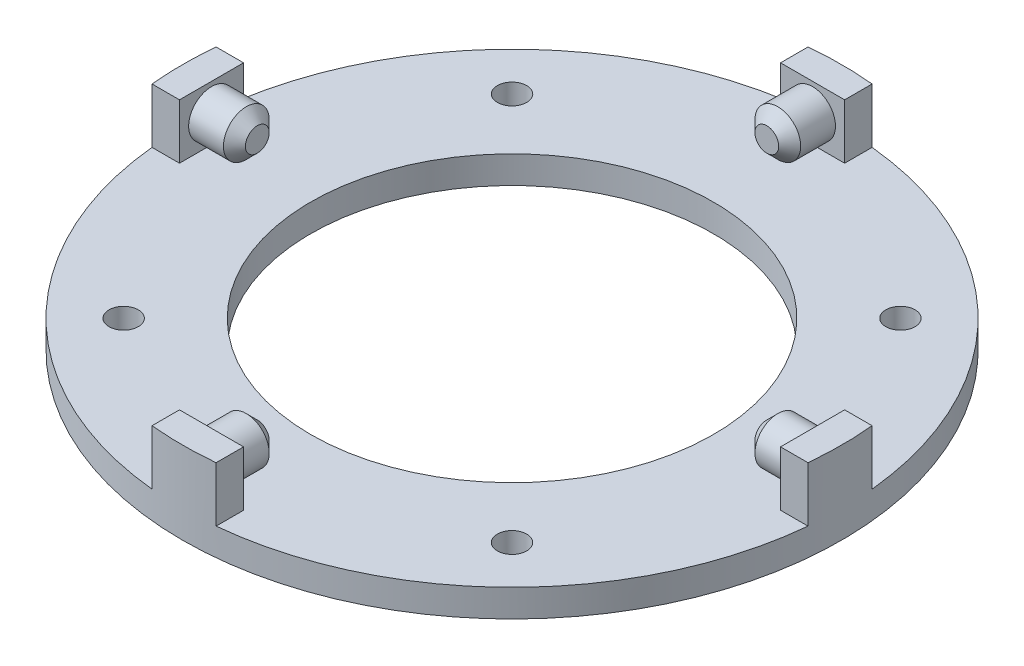
from build123d import *

# Parameters (mm, degrees)
SKETCH1_R                    = 36
SKETCH1_R_2                  = 22
BOSS_EXTRUDE1_DEPTH          = 3
BOSS_EXTRUDE2_DEPTH          = 6
SKETCH3_R                    = 2.5
BOSS_EXTRUDE3_DEPTH          = 5
CHAMFER1_SIZE                = 1.2
CIRPATTERN1_COUNT            = 4
CHAMFER1_OF_CIRPATTERN1_SIZE = 1.2
SKETCH4_R                    = 1.6
CUT_EXTRUDE1_DEPTH           = 3
CIRPATTERN2_COUNT            = 4


with BuildPart() as part:
    # Sketch1 → Boss-Extrude1 (new body)
    with BuildSketch(Plane(origin=(0, 0, 0), x_dir=(1, 0, 0), z_dir=(0, 1, 0))):
        Circle(SKETCH1_R)
        Circle(SKETCH1_R_2, mode=Mode.SUBTRACT)
    extrude(amount=BOSS_EXTRUDE1_DEPTH)

    # Sketch2 → Boss-Extrude2 (add)
    with BuildSketch(Plane(origin=(0, 3, 0), x_dir=(1, 0, 0), z_dir=(0, 1, 0))):
        with BuildLine():
            Line((-32.829457155, 3.5), (-35.829457155, 3.5))
            ThreePointArc((-35.829457155, 3.5), (-36, 0), (-35.829457155, -3.5))
            Line((-35.829457155, -3.5), (-32.829457155, -3.5))
            Line((-32.829457155, -3.5), (-32.829457155, 3.5))
        make_face()
    boss_extrude2 = extrude(amount=BOSS_EXTRUDE2_DEPTH)

    # Sketch3 → Boss-Extrude3 (add)
    with BuildSketch(Plane(origin=(-32.829457155, 0, 0), x_dir=(0, 0, -1), z_dir=(1, 0, 0))):
        with Locations((0, 6)):
            Circle(SKETCH3_R)
    boss_extrude3 = extrude(amount=BOSS_EXTRUDE3_DEPTH)

    # Chamfer1
    chamfer1_edges = [part.edges().sort_by_distance(p)[0] for p in [
        (-27.829457155, 6, 2.5),
    ]]
    chamfer(chamfer1_edges, length=CHAMFER1_SIZE)

    # CirPattern1: Boss-Extrude2, Boss-Extrude3 ×4 about axis
    cirpattern1_axis = Axis((0, 0, 0), (0, 1, 0))
    for i in range(1, CIRPATTERN1_COUNT):
        add(boss_extrude2.rotate(cirpattern1_axis, i * 360 / CIRPATTERN1_COUNT))
        add(boss_extrude3.rotate(cirpattern1_axis, i * 360 / CIRPATTERN1_COUNT))

    # Chamfer1 of CirPattern1
    chamfer1_of_cirpattern1_edges = [part.edges().sort_by_distance(p)[0] for p in [
        (2.5, 6, 27.829457155),
        (27.829457155, 6, -2.5),
        (-2.5, 6, -27.829457155),
    ]]
    chamfer(chamfer1_of_cirpattern1_edges, length=CHAMFER1_OF_CIRPATTERN1_SIZE)

    # Sketch4 → Cut-Extrude1 (cut)
    with BuildSketch(Plane(origin=(0, 3, 0), x_dir=(1, 0, 0), z_dir=(0, 1, 0))):
        with Locations((-21.213203436, 21.213203436)):
            Circle(SKETCH4_R)
    cut_extrude1 = extrude(amount=-CUT_EXTRUDE1_DEPTH, mode=Mode.SUBTRACT)

    # CirPattern2: Cut-Extrude1 ×4 about axis
    cirpattern2_axis = Axis((0, 0, 0), (0, 1, 0))
    for i in range(1, CIRPATTERN2_COUNT):
        add(cut_extrude1.rotate(cirpattern2_axis, i * 360 / CIRPATTERN2_COUNT), mode=Mode.SUBTRACT)


solid = part.part
